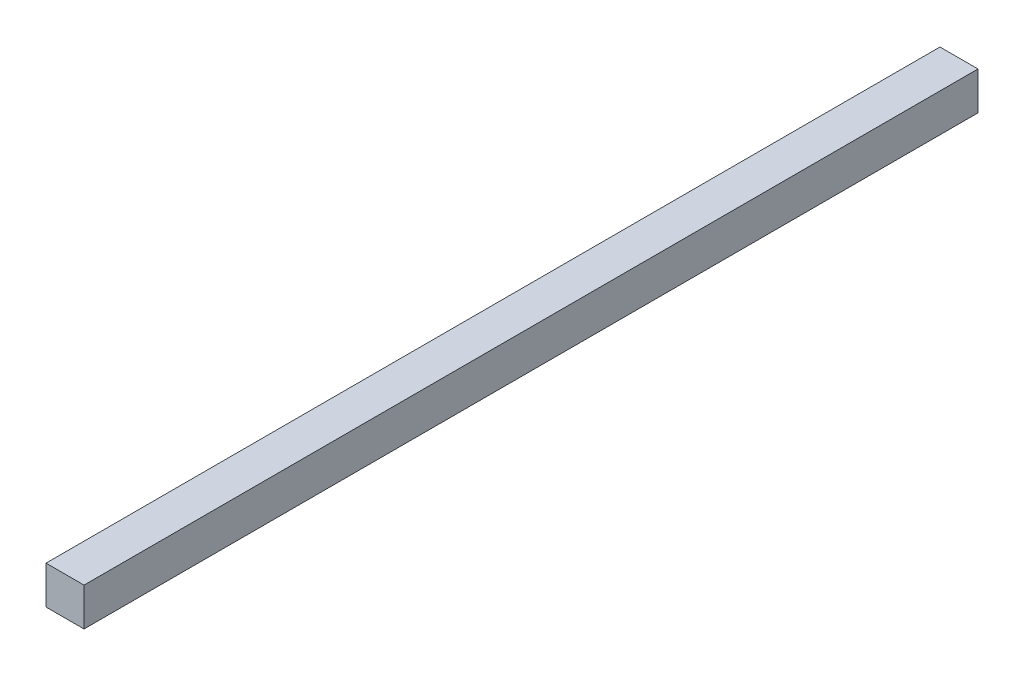
from build123d import *

# Parameters (mm, degrees)
SKETCH1_W           = 25.4
SKETCH1_H           = 25.4
BOSS_EXTRUDE1_DEPTH = 596.9


with BuildPart() as part:
    # Sketch1 → Boss-Extrude1 (new body)
    with BuildSketch(Plane.XY):
        Rectangle(SKETCH1_W, SKETCH1_H)
    extrude(amount=BOSS_EXTRUDE1_DEPTH)


solid = part.part
